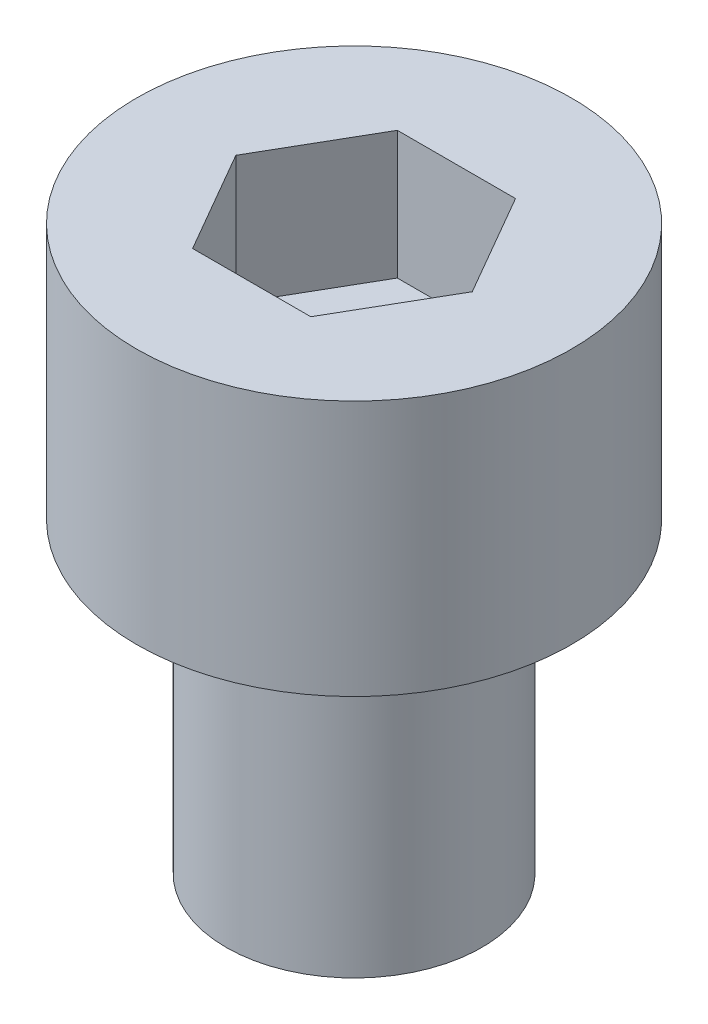
from build123d import *

# Parameters (mm, degrees)
SKETCH_1_R          = 4.25
EXTRUDE_1_DEPTH     = 5
CUT_EXTRUDE_1_DEPTH = 2.5
SKETCH_3_R          = 2.5
EXTRUDE_2_DEPTH     = 6


with BuildPart() as part:
    # 草图1 → 凸台-拉伸1 (new body)
    with BuildSketch(Plane(origin=(0, 0, 0), x_dir=(1, 0, 0), z_dir=(0, 1, 0))):
        Circle(SKETCH_1_R)
    extrude(amount=EXTRUDE_1_DEPTH)

    # 草图2 → 切除-拉伸1 (cut)
    with BuildSketch(Plane(origin=(0, 5, 0), x_dir=(1, 0, 0), z_dir=(0, 1, 0))):
        Polygon((2.309401077, 0), (1.154700538, 2), (-1.154700538, 2), (-2.309401077, 0), (-1.154700538, -2), (1.154700538, -2), align=None)
    extrude(amount=-CUT_EXTRUDE_1_DEPTH, mode=Mode.SUBTRACT)

    # 草图3 → 凸台-拉伸2 (add)
    with BuildSketch(Plane.XZ):
        Circle(SKETCH_3_R)
    extrude(amount=EXTRUDE_2_DEPTH)


solid = part.part
